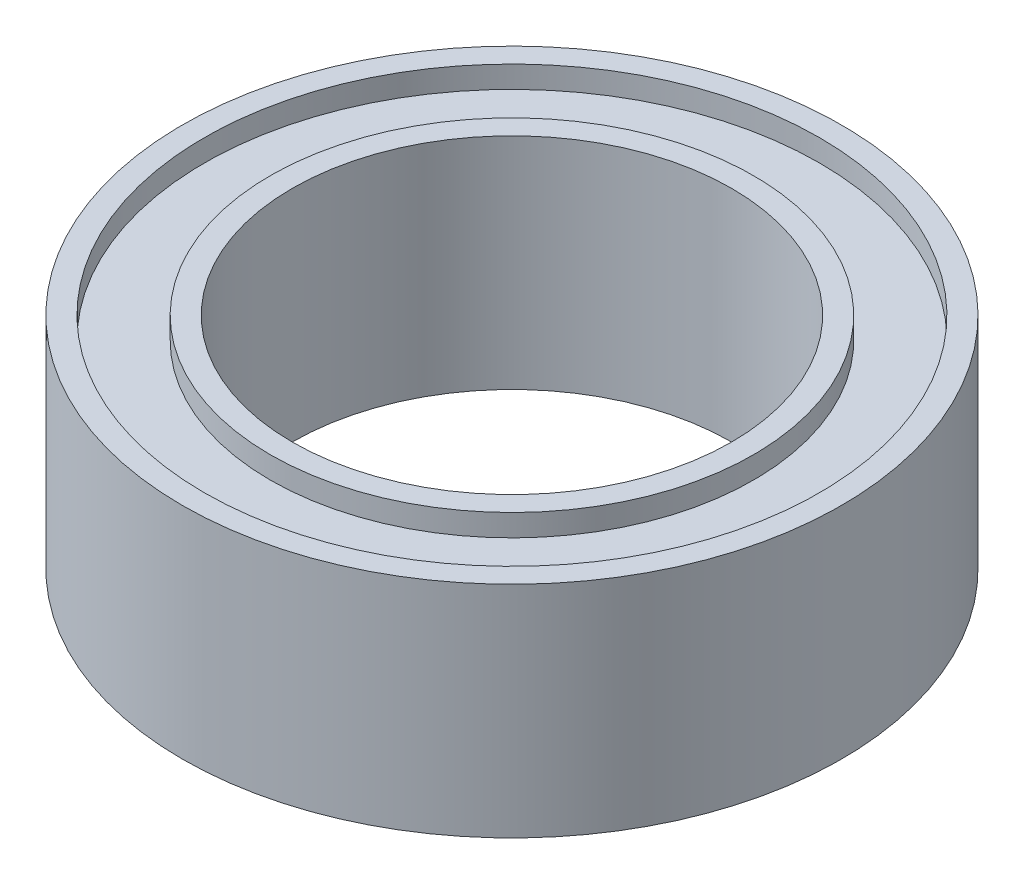
from build123d import *

# Parameters (mm, degrees)
SKETCH1_R           = 7.5
SKETCH1_R_2         = 5
BOSS_EXTRUDE1_DEPTH = 5
SKETCH2_R           = 7
SKETCH2_R_2         = 5.5
CUT_EXTRUDE1_DEPTH  = 0.5


with BuildPart() as part:
    # Sketch1 → Boss-Extrude1 (new body)
    with BuildSketch(Plane(origin=(0, 0, 0), x_dir=(1, 0, 0), z_dir=(0, 1, 0))):
        Circle(SKETCH1_R)
        Circle(SKETCH1_R_2, mode=Mode.SUBTRACT)
    extrude(amount=BOSS_EXTRUDE1_DEPTH)

    # Sketch2 → Cut-Extrude1 (cut)
    with BuildSketch(Plane(origin=(0, 5, 0), x_dir=(1, 0, 0), z_dir=(0, 1, 0))):
        Circle(SKETCH2_R)
        Circle(SKETCH2_R_2, mode=Mode.SUBTRACT)
    cut_extrude1 = extrude(amount=-CUT_EXTRUDE1_DEPTH, mode=Mode.SUBTRACT)

    # Mirror1: Cut-Extrude1 across plane
    add(cut_extrude1.mirror(Plane(origin=(0, 2.5, 0), x_dir=(0, 0, 1), z_dir=(0, -1, 0))), mode=Mode.SUBTRACT)


solid = part.part
